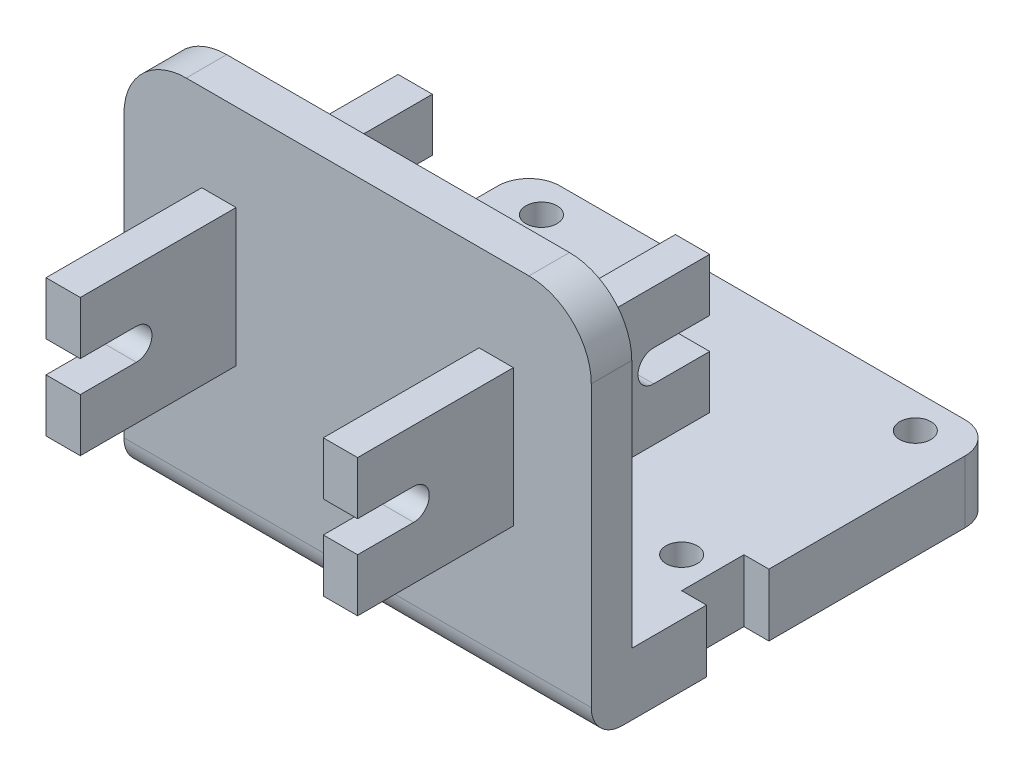
from build123d import *

# Parameters (mm, degrees)
SKETCH1_W            = 75
SKETCH1_H            = 55
SKETCH1_R            = 2.5
BOSS_EXTRUDE1_DEPTH  = 10
SKETCH7_W            = 75
SKETCH7_H            = 10
BOSS_EXTRUDE2_DEPTH  = 60
SKETCH9_W            = 75
SKETCH9_H            = 3.5
CUT_EXTRUDE5_DEPTH   = 50
FILLET3_R            = 5
FILLET4_R            = 5
SKETCH10_W           = 46
SKETCH10_H           = 30
BOSS_EXTRUDE3_DEPTH  = 21
SKETCH11_W           = 36
SKETCH11_H           = 16
CUT_EXTRUDE6_DEPTH   = 51
SKETCH12_W           = 46
SKETCH12_H           = 30
BOSS_EXTRUDE4_DEPTH  = 21
CUT_EXTRUDE7_REACH   = 52
SKETCH14_W           = 36
SKETCH14_H           = 16
CUT_EXTRUDE9_DEPTH   = 30
SKETCH17_W           = 21
SKETCH17_H           = 4
CUT_EXTRUDE10_DEPTH  = 61.5
BOSS_EXTRUDE5_DEPTH  = 2
BOSS_EXTRUDE6_DEPTH  = 2
BOSS_EXTRUDE7_DEPTH  = 2
BOSS_EXTRUDE8_DEPTH  = 2
SKETCH22_W           = 5.5
SKETCH22_H           = 8.5
BOSS_EXTRUDE9_DEPTH  = 4
SKETCH23_W           = 5.5
SKETCH23_H           = 8.5
BOSS_EXTRUDE10_DEPTH = 4
FILLET5_R            = 10
SKETCH25_W           = 4
SKETCH25_H           = 4
SKETCH25_H_2         = 2
CUT_EXTRUDE11_DEPTH  = 11
SKETCH27_R           = 2.5
CUT_EXTRUDE14_DEPTH  = 11


with BuildPart() as part:
    # Sketch1 → Boss-Extrude1 (new body)
    with BuildSketch(Plane(origin=(0, 0, 0), x_dir=(1, 0, 0), z_dir=(0, 1, 0))):
        Rectangle(SKETCH1_W, SKETCH1_H)
        with Locations((-30, 22)):
            Circle(SKETCH1_R, mode=Mode.SUBTRACT)
        with Locations((30, 22)):
            Circle(SKETCH1_R, mode=Mode.SUBTRACT)
        with Locations((0, -16.5)):
            Circle(SKETCH1_R, mode=Mode.SUBTRACT)
    extrude(amount=BOSS_EXTRUDE1_DEPTH)

    # Sketch7 → Boss-Extrude2 (add)
    with BuildSketch(Plane(origin=(0, 0, 0), x_dir=(1, 0, 0), z_dir=(0, 1, 0))):
        with Locations((0, -32.5)):
            Rectangle(SKETCH7_W, SKETCH7_H)
    extrude(amount=BOSS_EXTRUDE2_DEPTH)

    # Sketch9 → Cut-Extrude5 (cut)
    with BuildSketch(Plane(origin=(0, 60, 0), x_dir=(1, 0, 0), z_dir=(0, 1, 0))):
        with Locations((0, -29.25)):
            Rectangle(SKETCH9_W, SKETCH9_H)
    extrude(amount=-CUT_EXTRUDE5_DEPTH, mode=Mode.SUBTRACT)

    # Fillet3
    fillet3_edges = [part.edges().sort_by_distance(p)[0] for p in [
        (0, 0, 37.5),
    ]]
    fillet(fillet3_edges, radius=FILLET3_R)

    # Fillet4
    fillet4_edges = [part.edges().sort_by_distance(p)[0] for p in [
        (-37.5, 5, -27.5),
        (37.5, 5, -27.5),
    ]]
    fillet(fillet4_edges, radius=FILLET4_R)

    # Sketch10 → Boss-Extrude3 (add)
    with BuildSketch(Plane.XY.offset(37.5)):
        with Locations((0, 35)):
            Rectangle(SKETCH10_W, SKETCH10_H)
    extrude(amount=BOSS_EXTRUDE3_DEPTH)

    # Sketch11 → Cut-Extrude6 (cut, through all)
    with BuildSketch(Plane(origin=(0, 50, 0), x_dir=(1, 0, 0), z_dir=(0, 1, 0))):
        with Locations((0, -45.5)):
            Rectangle(SKETCH11_W, SKETCH11_H)
    extrude(amount=-CUT_EXTRUDE6_DEPTH, mode=Mode.SUBTRACT)

    # Sketch12 → Boss-Extrude4 (add)
    with BuildSketch(Plane(origin=(0, 0, 31), x_dir=(-1, 0, 0), z_dir=(0, 0, -1))):
        with Locations((0, 35)):
            Rectangle(SKETCH12_W, SKETCH12_H)
    extrude(amount=BOSS_EXTRUDE4_DEPTH)

    # Sketch14 → Cut-Extrude7 (cut, up to next)
    with BuildSketch(Plane(origin=(0, 50, 0), x_dir=(1, 0, 0), z_dir=(0, 1, 0)), mode=Mode.PRIVATE) as cut_extrude7_sk1:
        with Locations((0, -23)):
            Rectangle(SKETCH14_W, SKETCH14_H)
    cut_extrude7_tool1 = extrude(cut_extrude7_sk1.sketch, amount=-CUT_EXTRUDE7_REACH, mode=Mode.PRIVATE) & part.part
    add(cut_extrude7_tool1.solids().sort_by_distance((0, 50, 23))[0], mode=Mode.SUBTRACT)

    # Sketch16 → Cut-Extrude9 (cut)
    with BuildSketch(Plane(origin=(0, 50, 0), x_dir=(1, 0, 0), z_dir=(0, 1, 0))):
        Polygon((-19.5, -31), (-19.5, -12.885372955), (-19.5, -10), (19.5, -9.896863532), (19.5, -31), align=None)
        Polygon((19.5, -58.603136468), (19.5, -37.5), (-19.5, -37.5), (-19.5, -55.614627045), (-19.5, -58.5), align=None)
    extrude(amount=-CUT_EXTRUDE9_DEPTH, mode=Mode.SUBTRACT)

    # Sketch17 → Cut-Extrude10 (cut, through all)
    with BuildSketch(Plane.ZY.offset(23)):
        with Locations((48, 48)):
            Rectangle(SKETCH17_W, SKETCH17_H)
        with BuildLine():
            ThreePointArc((53.5, 32.5), (51, 35), (53.5, 37.5))
            Line((53.5, 37.5), (58.5, 37.5))
            Line((58.5, 37.5), (58.5, 32.5))
            Line((58.5, 32.5), (53.5, 32.5))
        make_face()
        with Locations((48, 22)):
            Rectangle(SKETCH17_W, SKETCH17_H)
        with Locations((20.5, 48)):
            Rectangle(SKETCH17_W, SKETCH17_H)
        with BuildLine():
            Line((10, 37.5), (10, 32.5))
            Line((10, 32.5), (15, 32.5))
            ThreePointArc((15, 32.5), (17.5, 35), (15, 37.5))
            Line((15, 37.5), (10, 37.5))
        make_face()
        with Locations((20.5, 22)):
            Rectangle(SKETCH17_W, SKETCH17_H)
    extrude(amount=-CUT_EXTRUDE10_DEPTH, mode=Mode.SUBTRACT)

    # Sketch18 → Boss-Extrude5 (add)
    with BuildSketch(Plane.ZY.offset(23)):
        with BuildLine():
            Line((31, 24), (31, 46))
            Line((31, 46), (10, 46))
            Line((10, 46), (10, 37.5))
            Line((10, 37.5), (15, 37.5))
            ThreePointArc((15, 37.5), (17.5, 35), (15, 32.5))
            Line((15, 32.5), (10, 32.5))
            Line((10, 32.5), (10, 24))
            Line((10, 24), (31, 24))
        make_face()
    extrude(amount=BOSS_EXTRUDE5_DEPTH)

    # Sketch19 → Boss-Extrude6 (add)
    with BuildSketch(Plane(origin=(23, 0, 0), x_dir=(0, 0, -1), z_dir=(1, 0, 0))):
        with BuildLine():
            Line((-10, 37.5), (-10, 46))
            Line((-10, 46), (-31, 46))
            Line((-31, 46), (-31, 24))
            Line((-31, 24), (-10, 24))
            Line((-10, 24), (-10, 32.5))
            Line((-10, 32.5), (-15, 32.5))
            ThreePointArc((-15, 32.5), (-17.5, 35), (-15, 37.5))
            Line((-15, 37.5), (-10, 37.5))
        make_face()
    extrude(amount=BOSS_EXTRUDE6_DEPTH)

    # Sketch20 → Boss-Extrude7 (add)
    with BuildSketch(Plane.ZY.offset(23)):
        with BuildLine():
            Line((53.5, 37.5), (58.5, 37.5))
            Line((58.5, 37.5), (58.5, 46))
            Line((58.5, 46), (37.5, 46))
            Line((37.5, 46), (37.5, 24))
            Line((37.5, 24), (58.5, 24))
            Line((58.5, 24), (58.5, 32.5))
            Line((58.5, 32.5), (53.5, 32.5))
            ThreePointArc((53.5, 32.5), (51, 35), (53.5, 37.5))
        make_face()
    extrude(amount=BOSS_EXTRUDE7_DEPTH)

    # Sketch21 → Boss-Extrude8 (add)
    with BuildSketch(Plane(origin=(23, 0, 0), x_dir=(0, 0, -1), z_dir=(1, 0, 0))):
        with BuildLine():
            Line((-58.5, 37.5), (-53.5, 37.5))
            ThreePointArc((-53.5, 37.5), (-51, 35), (-53.5, 32.5))
            Line((-53.5, 32.5), (-58.5, 32.5))
            Line((-58.5, 32.5), (-58.5, 24))
            Line((-58.5, 24), (-37.5, 24))
            Line((-37.5, 24), (-37.5, 46))
            Line((-37.5, 46), (-58.5, 46))
            Line((-58.5, 46), (-58.5, 37.5))
        make_face()
    extrude(amount=BOSS_EXTRUDE8_DEPTH)

    # Sketch22 → Boss-Extrude9 (add)
    with BuildSketch(Plane(origin=(0, 0, 10), x_dir=(-1, 0, 0), z_dir=(0, 0, -1))):
        with Locations((22.25, 28.25)):
            Rectangle(SKETCH22_W, SKETCH22_H)
        with Locations((22.25, 41.75)):
            Rectangle(SKETCH22_W, SKETCH22_H)
        with Locations((-22.25, 28.25)):
            Rectangle(SKETCH22_W, SKETCH22_H)
        with Locations((-22.25, 41.75)):
            Rectangle(SKETCH22_W, SKETCH22_H)
    extrude(amount=BOSS_EXTRUDE9_DEPTH)

    # Sketch23 → Boss-Extrude10 (add)
    with BuildSketch(Plane.XY.offset(58.5)):
        with Locations((22.25, 28.25)):
            Rectangle(SKETCH23_W, SKETCH23_H)
        with Locations((22.25, 41.75)):
            Rectangle(SKETCH23_W, SKETCH23_H)
        with Locations((-22.25, 28.25)):
            Rectangle(SKETCH23_W, SKETCH23_H)
        with Locations((-22.25, 41.75)):
            Rectangle(SKETCH23_W, SKETCH23_H)
    extrude(amount=BOSS_EXTRUDE10_DEPTH)

    # Fillet5
    fillet5_edges = [part.edges().sort_by_distance(p)[0] for p in [
        (37.5, 60, 34.25),
        (-37.5, 60, 34.25),
    ]]
    fillet(fillet5_edges, radius=FILLET5_R)

    # Sketch25 → Cut-Extrude11 (cut, through all)
    with BuildSketch(Plane(origin=(0, 10, 0), x_dir=(1, 0, 0), z_dir=(0, 1, 0))):
        with Locations((-35.5, -11)):
            Rectangle(SKETCH25_W, SKETCH25_H)
        with Locations((-35.5, -14)):
            Rectangle(SKETCH25_W, SKETCH25_H_2)
        with Locations((-35.5, -17)):
            Rectangle(SKETCH25_W, SKETCH25_H)
        with Locations((35.5, -11)):
            Rectangle(SKETCH25_W, SKETCH25_H)
        with Locations((35.5, -14)):
            Rectangle(SKETCH25_W, SKETCH25_H_2)
        with Locations((35.5, -17)):
            Rectangle(SKETCH25_W, SKETCH25_H)
    extrude(amount=-CUT_EXTRUDE11_DEPTH, mode=Mode.SUBTRACT)

    # Sketch27 → Cut-Extrude14 (cut, through all)
    with BuildSketch(Plane(origin=(0, 10, 0), x_dir=(1, 0, 0), z_dir=(0, 1, 0))):
        with Locations((-28.5, -14)):
            Circle(SKETCH27_R)
        with Locations((28.5, -14)):
            Circle(SKETCH27_R)
    extrude(amount=-CUT_EXTRUDE14_DEPTH, mode=Mode.SUBTRACT)


solid = part.part
